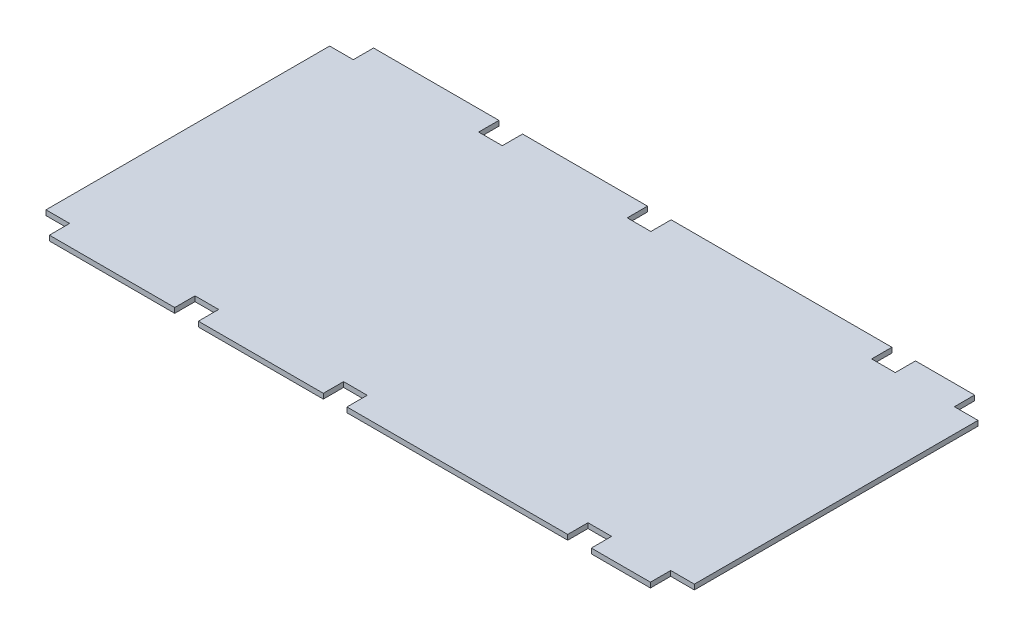
from build123d import *

# Parameters (mm, degrees)
SKETCH1_W           = 2438.4
SKETCH1_H           = 1219.2
BOSS_EXTRUDE1_DEPTH = 9.525
SKETCH2_W           = 88.9
SKETCH2_H           = 76.2
CUT_EXTRUDE1_DEPTH  = 20.05


with BuildPart() as part:
    # Sketch1 → Boss-Extrude1 (new body, symmetric)
    with BuildSketch(Plane(origin=(0, 0, 0), x_dir=(1, 0, 0), z_dir=(0, 1, 0))):
        with Locations((1219.2, 609.6)):
            Rectangle(SKETCH1_W, SKETCH1_H)
    extrude(amount=BOSS_EXTRUDE1_DEPTH, both=True)

    # Sketch2 → Cut-Extrude1 (cut, through all)
    with BuildSketch(Plane(origin=(0, 9.525, 0), x_dir=(1, 0, 0), z_dir=(0, 1, 0))):
        with Locations((44.45, 1181.1)):
            Rectangle(SKETCH2_W, SKETCH2_H)
        with Locations((604.8375, 1181.1)):
            Rectangle(SKETCH2_W, SKETCH2_H)
        with Locations((1163.6375, 1181.1)):
            Rectangle(SKETCH2_W, SKETCH2_H)
        with Locations((2082.8, 1181.1)):
            Rectangle(SKETCH2_W, SKETCH2_H)
        with Locations((2393.95, 1181.1)):
            Rectangle(SKETCH2_W, SKETCH2_H)
        with Locations((1163.6375, 38.1)):
            Rectangle(SKETCH2_W, SKETCH2_H)
        with Locations((604.8375, 38.1)):
            Rectangle(SKETCH2_W, SKETCH2_H)
        with Locations((2393.95, 38.1)):
            Rectangle(SKETCH2_W, SKETCH2_H)
        with Locations((2082.8, 38.1)):
            Rectangle(SKETCH2_W, SKETCH2_H)
        with Locations((44.45, 38.1)):
            Rectangle(SKETCH2_W, SKETCH2_H)
    extrude(amount=-CUT_EXTRUDE1_DEPTH, mode=Mode.SUBTRACT)


solid = part.part
